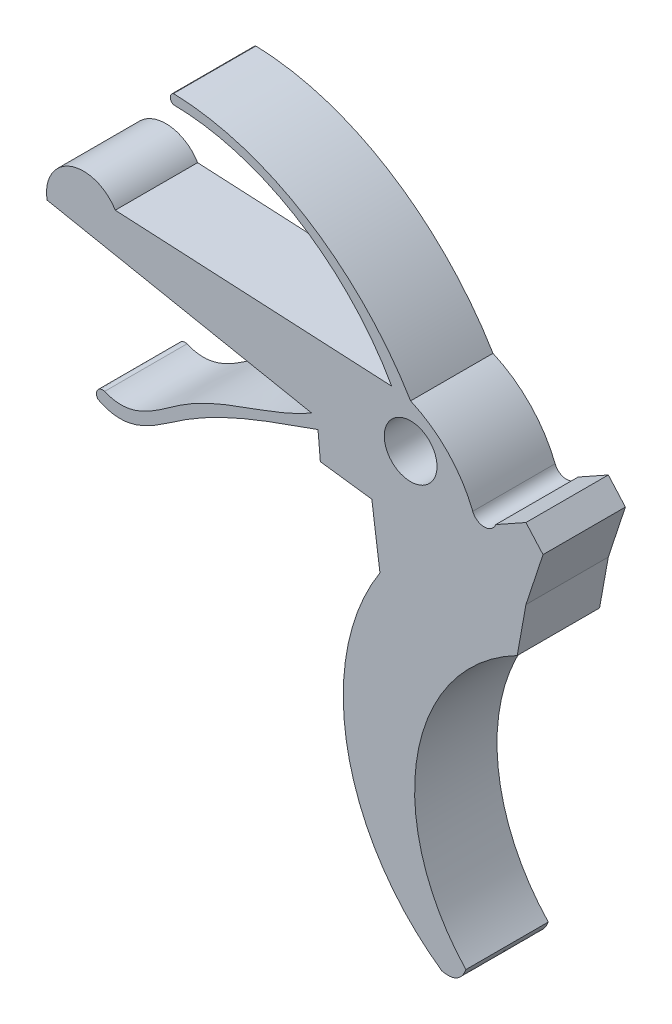
from build123d import *

# Parameters (mm, degrees)
ESQUISSE1_R        = 1.6
BOSS_EXTRU_1_DEPTH = 5


with BuildPart() as part:
    # Esquisse1 → Boss.-Extru.1 (new body)
    with BuildSketch(Plane.XY):
        with BuildLine():
            Line((22.327201908, 31.379603837), (39.110435041, 30.51970557))
            add(Edge.make_bspline(
                [(39.110435041, 30.51970557), (36.47036177, 35.234015671), (31.363758289, 38.634202101), (25.860213157, 38.692785858)],
                knots=[0, 0, 0, 0, 1, 1, 1, 1], degree=3))
            ThreePointArc((25.860213157, 38.692785858), (25.667702993, 38.985657248), (25.860213157, 39.278528639))
            add(Edge.make_bspline(
                [(40.257442964, 30.322056107), (37.254594876, 35.338660309), (31.834783082, 39.118012576), (25.860213157, 39.278528639)],
                knots=[0, 0, 0, 0, 1, 1, 1, 1], degree=3))
            ThreePointArc((40.257442964, 30.322056107), (42.530790825, 28.735523525), (44.029353415, 26.403248607))
            ThreePointArc((44.029353415, 26.403248607), (44.727102443, 25.92851016), (45.42485147, 26.403248607))
            Line((45.42485147, 26.403248607), (47.257362462, 27.428768466))
            Line((47.257362462, 27.428768466), (48.294348688, 26.259658274))
            Line((48.294348688, 26.259658274), (47.257362462, 23.11213505))
            Line((47.257362462, 23.11213505), (46.726853729, 20.169285321))
            ThreePointArc((46.726853729, 20.169285321), (40.667605427, 11.913133381), (43.612357696, 2.104618258))
            add(Edge.make_bspline(
                [(42.15327541, 1.306168032), (43.216115527, 1.058074746), (43.612357696, 2.104618258)],
                knots=[0, 0, 0, 1, 1, 1], degree=2))
            ThreePointArc((42.15327541, 1.306168032), (36.433188896, 10.069245024), (38.395197552, 20.348419608))
            Line((38.395197552, 20.348419608), (37.901995747, 23.976769729))
            Line((37.901995747, 23.976769729), (34.777422909, 24.385367715))
            Line((34.777422909, 24.385367715), (34.63683293, 26.004711162))
            add(Edge.make_bspline(
                [(34.63683293, 26.004711162), (31.667222126, 24.941467321), (27.310515623, 23.524901716), (23.172641891, 19.922056798), (21.279549959, 20.917906985)],
                knots=[0, 0, 0, 0, 0.624834994, 1, 1, 1, 1], degree=3))
            ThreePointArc((21.279549959, 20.917906985), (21.246108661, 21.381188034), (21.68443358, 21.534872503))
            add(Edge.make_bspline(
                [(34.253498198, 26.678639313), (31.663787476, 25.192133844), (27.282995796, 24.602462594), (23.471926653, 20.784486953), (21.68443358, 21.534872503)],
                knots=[0, 0, 0, 0, 0.618454585, 1, 1, 1, 1], degree=3))
            Line((34.253498198, 26.678639313), (18.193151692, 29.841352594))
            ThreePointArc((18.193151692, 29.841352594), (19.619419184, 32.332514308), (22.327201908, 31.379603837))
        make_face()
        with Locations((40.257442964, 27.673893027)):
            Circle(ESQUISSE1_R, mode=Mode.SUBTRACT)
    extrude(amount=BOSS_EXTRU_1_DEPTH)


solid = part.part
